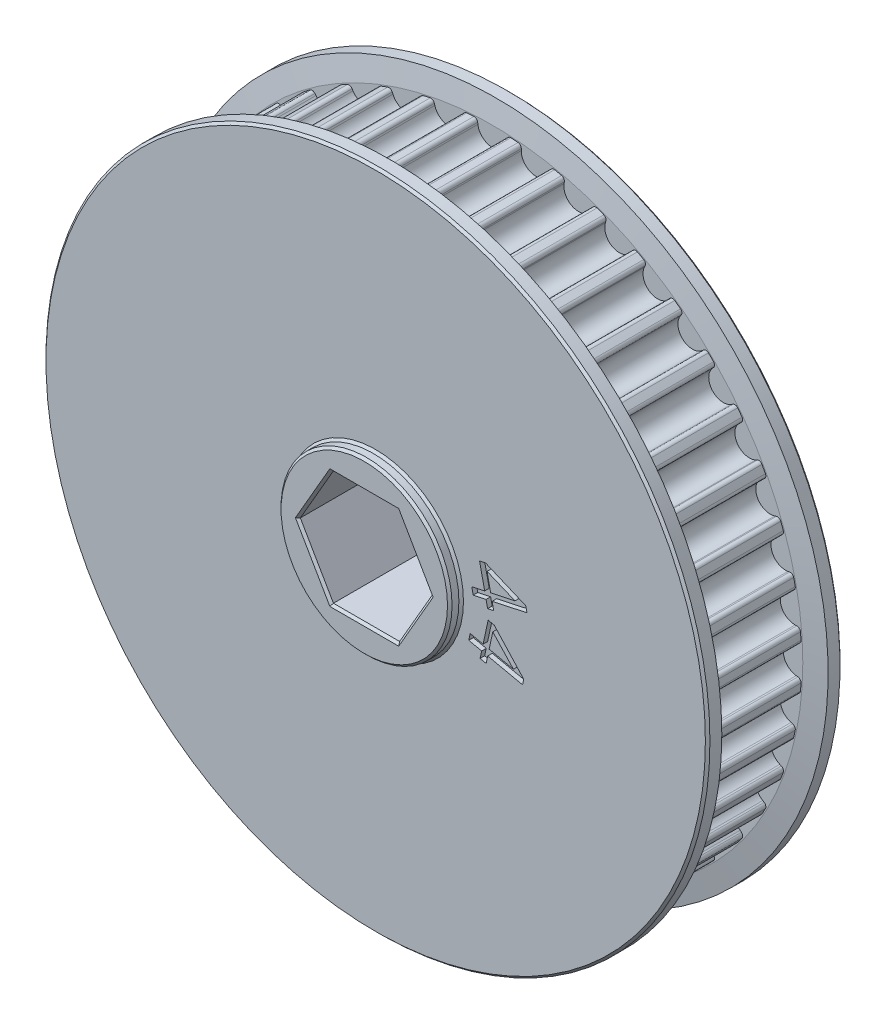
from build123d import *

# Parameters (mm, degrees)
SKETCH2_R                                 = 34.443854385
PULLEY_DEPTH                              = 5.500000049
CUT_TOOTH_DEPTH                           = 5.500000049
BLEND_TOOTH_R                             = 0.4
TOOTH_PATTERN_COUNT                       = 44
BLEND_TOOTH_OF_TOOTH_PATTERN_R            = 0.4
SIDEWALL_START                            = 5.500000049
SKETCH3_R                                 = 36.983854385
SIDEWALL_DEPTH                            = 2.000000064
SIDEWALL_CHAMFER_SIZE                     = 2.400000026
SIDEWALL_CHAMFER_SIZE2                    = 0.423184758
SIDEWALL_CHAMFER_PART_2_SIZE              = 2.400000026
SIDEWALL_CHAMFER_PART_2_SIZE2             = 0.423184758
SKETCH5_R                                 = 9.525
BEARING_SPACER_MANUAL_SUPPRESS_DEPTH      = 8.770000113
BEARING_SPACER_MANUAL_SUPPRESS_DEPTH_BACK = 8.770000113
HEX_SHAFT_DEPTH                           = 63.5
CHAMFERS_SIZE                             = 0.254
CUT_EXTRUDE_START                         = 6.992000113
CUT_EXTRUDE_4419_DEPTH                    = 2.54
SKETCH7_R                                 = 28.575
SKETCH7_R_2                               = 22.225
PATH_FOR_MOTOR_S_BOLTS_DEPTH              = 3.175


with BuildPart() as part:
    # Sketch2 → pulley (new body, symmetric)
    with BuildSketch(Plane.XY):
        Circle(SKETCH2_R)
    extrude(amount=PULLEY_DEPTH, both=True)

    # tooth → cut tooth (cut, symmetric)
    with BuildSketch(Plane.XY):
        with BuildLine():
            Line((-2.132711961, 38.079446832), (-1.612887548, 33.845816734))
            ThreePointArc((-1.612887548, 33.845816734), (0, 32.418854371), (1.612887548, 33.845816734))
            Line((1.612887548, 33.845816734), (2.132711961, 38.079446832))
            Line((2.132711961, 38.079446832), (-2.132711961, 38.079446832))
        make_face()
    cut_tooth = extrude(amount=CUT_TOOTH_DEPTH, both=True, mode=Mode.SUBTRACT)

    # blend tooth
    blend_tooth_edges = [part.edges().sort_by_distance(p)[0] for p in [
        (1.681276079, 34.402796626, 0),
        (-1.681276079, 34.402796626, 0),
    ]]
    fillet(blend_tooth_edges, radius=BLEND_TOOTH_R)

    # tooth pattern: cut tooth ×44 about axis
    tooth_pattern_axis = Axis((0, 0, 0), (0, 0, 1))
    for i in range(1, TOOTH_PATTERN_COUNT):
        add(cut_tooth.rotate(tooth_pattern_axis, i * 360 / TOOTH_PATTERN_COUNT), mode=Mode.SUBTRACT)

    # blend tooth of tooth pattern
    blend_tooth_of_tooth_pattern_edges = [part.edges().sort_by_distance(p)[0] for p in [
        (-3.231865325, 34.291896294, 0),
        (-6.560191551, 33.813355227, 0),
        (-8.079215271, 33.482911844, 0),
        (-11.305560441, 32.535571426, 0),
        (-12.762095693, 31.992311865, 0),
        (-15.820780722, 30.595457216, 0),
        (-17.185176649, 29.850440675, 0),
        (-20.013935532, 28.032507727, 0),
        (-21.258416967, 27.100900594, 0),
        (-23.799664329, 24.898897219, 0),
        (-24.898897219, 23.799664329, 0),
        (-27.100900594, 21.258416967, 0),
        (-28.032507727, 20.013935532, 0),
        (-29.850440675, 17.185176649, 0),
        (-30.595457216, 15.820780722, 0),
        (-31.992311865, 12.762095693, 0),
        (-32.535571426, 11.305560441, 0),
        (-33.482911844, 8.079215271, 0),
        (-33.813355227, 6.560191551, 0),
        (-34.291896294, 3.231865325, 0),
        (-34.402796626, 1.681276079, 0),
        (-34.402796626, -1.681276079, 0),
        (-34.291896294, -3.231865325, 0),
        (-33.813355227, -6.560191551, 0),
        (-33.482911844, -8.079215271, 0),
        (-32.535571426, -11.305560441, 0),
        (-31.992311865, -12.762095693, 0),
        (-30.595457216, -15.820780722, 0),
        (-29.850440675, -17.185176649, 0),
        (-28.032507727, -20.013935532, 0),
        (-27.100900594, -21.258416967, 0),
        (-24.898897219, -23.799664329, 0),
        (-23.799664329, -24.898897219, 0),
        (-21.258416967, -27.100900594, 0),
        (-20.013935532, -28.032507727, 0),
        (-17.185176649, -29.850440675, 0),
        (-15.820780722, -30.595457216, 0),
        (-12.762095693, -31.992311865, 0),
        (-11.305560441, -32.535571426, 0),
        (-8.079215271, -33.482911844, 0),
        (-6.560191551, -33.813355227, 0),
        (-3.231865325, -34.291896294, 0),
        (-1.681276079, -34.402796626, 0),
        (1.681276079, -34.402796626, 0),
        (3.231865325, -34.291896294, 0),
        (6.560191551, -33.813355227, 0),
        (8.079215271, -33.482911844, 0),
        (11.305560441, -32.535571426, 0),
        (12.762095693, -31.992311865, 0),
        (15.820780722, -30.595457216, 0),
        (17.185176649, -29.850440675, 0),
        (20.013935532, -28.032507727, 0),
        (21.258416967, -27.100900594, 0),
        (23.799664329, -24.898897219, 0),
        (24.898897219, -23.799664329, 0),
        (27.100900594, -21.258416967, 0),
        (28.032507727, -20.013935532, 0),
        (29.850440675, -17.185176649, 0),
        (30.595457216, -15.820780722, 0),
        (31.992311865, -12.762095693, 0),
        (32.535571426, -11.305560441, 0),
        (33.482911844, -8.079215271, 0),
        (33.813355227, -6.560191551, 0),
        (34.291896294, -3.231865325, 0),
        (34.402796626, -1.681276079, 0),
        (34.402796626, 1.681276079, 0),
        (34.291896294, 3.231865325, 0),
        (33.813355227, 6.560191551, 0),
        (33.482911844, 8.079215271, 0),
        (32.535571426, 11.305560441, 0),
        (31.992311865, 12.762095693, 0),
        (30.595457216, 15.820780722, 0),
        (29.850440675, 17.185176649, 0),
        (28.032507727, 20.013935532, 0),
        (27.100900594, 21.258416967, 0),
        (24.898897219, 23.799664329, 0),
        (23.799664329, 24.898897219, 0),
        (21.258416967, 27.100900594, 0),
        (20.013935532, 28.032507727, 0),
        (17.185176649, 29.850440675, 0),
        (15.820780722, 30.595457216, 0),
        (12.762095693, 31.992311865, 0),
        (11.305560441, 32.535571426, 0),
        (8.079215271, 33.482911844, 0),
        (6.560191551, 33.813355227, 0),
        (3.231865325, 34.291896294, 0),
    ]]
    fillet(blend_tooth_of_tooth_pattern_edges, radius=BLEND_TOOTH_OF_TOOTH_PATTERN_R)

    # Sketch3 → sidewall (add)
    with BuildSketch(Plane.XY.offset(SIDEWALL_START)):
        Circle(SKETCH3_R)
    sidewall = extrude(amount=SIDEWALL_DEPTH)

    # mirror sidewall: sidewall across plane
    add(sidewall.mirror(Plane.XY))

    # sidewall chamfer
    sidewall_chamfer_edges = [part.edges().sort_by_distance(p)[0] for p in [
        (-36.983854385, 0, 5.500000049),
    ]]
    sidewall_chamfer_side = [part.faces().sort_by_distance(p)[0] for p in [
        (-35.937793016, 0, 5.500000049),
    ]]
    chamfer(sidewall_chamfer_edges, length=SIDEWALL_CHAMFER_SIZE, length2=SIDEWALL_CHAMFER_SIZE2, reference=sidewall_chamfer_side[0])

    # sidewall chamfer part 2
    sidewall_chamfer_part_2_edges = [part.edges().sort_by_distance(p)[0] for p in [
        (-36.983854385, 0, -5.500000049),
    ]]
    sidewall_chamfer_part_2_side = [part.faces().sort_by_distance(p)[0] for p in [
        (-35.937793016, 0, -5.500000049),
    ]]
    chamfer(sidewall_chamfer_part_2_edges, length=SIDEWALL_CHAMFER_PART_2_SIZE, length2=SIDEWALL_CHAMFER_PART_2_SIZE2, reference=sidewall_chamfer_part_2_side[0])

    # Sketch5 → bearing spacer (Manual Suppress) (add, two sides)
    with BuildSketch(Plane.XY) as bearing_spacer_manual_suppress_sk:
        Circle(SKETCH5_R)
    extrude(amount=BEARING_SPACER_MANUAL_SUPPRESS_DEPTH)
    extrude(bearing_spacer_manual_suppress_sk.sketch, amount=-BEARING_SPACER_MANUAL_SUPPRESS_DEPTH_BACK)

    # Sketch4 → hex shaft (cut, symmetric)
    with BuildSketch(Plane.XY):
        Polygon((3.688171255, 6.3881), (-3.688171255, 6.3881), (-7.376342509, 0), (-3.688171255, -6.3881), (3.688171255, -6.3881), (7.376342509, 0), align=None)
    extrude(amount=HEX_SHAFT_DEPTH, both=True, mode=Mode.SUBTRACT)

    # chamfers
    chamfers_edges = [part.edges().sort_by_distance(p)[0] for p in [
        (-36.983854385, 0, 7.500000113),
        (-36.983854385, 0, -7.500000113),
        (-9.525, 0, -7.500000113),
        (-9.525, 0, 7.500000113),
        (-9.525, 0, -8.770000113),
        (-9.525, 0, 8.770000113),
        (0, 6.3881, 8.770000113),
        (-5.532256882, 3.19405, 8.770000113),
        (-5.532256882, -3.19405, 8.770000113),
        (0, -6.3881, 8.770000113),
        (5.532256882, -3.19405, 8.770000113),
        (5.532256882, 3.19405, 8.770000113),
        (5.532256882, 3.19405, -8.770000113),
        (5.532256882, -3.19405, -8.770000113),
        (0, -6.3881, -8.770000113),
        (-5.532256882, -3.19405, -8.770000113),
        (-5.532256882, 3.19405, -8.770000113),
        (0, 6.3881, -8.770000113),
    ]]
    chamfer(chamfers_edges, length=CHAMFERS_SIZE)

    # Sketch6 → 4419 (cut)
    with BuildSketch(Plane.XY.offset(CUT_EXTRUDE_START)):
        Polygon((10.702258848, 1.896432721), (12.138294728, 2.206359639), (11.576475016, 4.808017076), (12.25065867, 4.953719771), (16.727929609, 3.058349972), (16.857580311, 2.457017665), (12.971763532, 1.616140249), (13.147100673, 0.806132048), (12.472917018, 0.660429354), (12.297579877, 1.470437554), (10.861543997, 1.160510636), align=None)
        Polygon((12.812478383, 2.352062334), (15.516621613, 2.937342649), (12.406239514, 4.230145372), align=None, mode=Mode.SUBTRACT)
        Polygon((10.530143712, -2.707847537), (11.966179592, -3.017774455), (12.527999304, -0.416117018), (13.202182959, -0.561819712), (16.49654558, -4.138944342), (16.366894877, -4.74027665), (12.481078097, -3.899399234), (12.305740956, -4.709407435), (11.631557302, -4.56370474), (11.806894443, -3.75369654), (10.370858562, -3.443769621), align=None)
        Polygon((12.640363247, -3.16347715), (15.344506477, -3.748757465), (13.046602115, -1.285394111), align=None, mode=Mode.SUBTRACT)
    extrude(amount=CUT_EXTRUDE_4419_DEPTH, mode=Mode.SUBTRACT)

    # Sketch7 → Path for motor's bolts (cut)
    with BuildSketch(Plane(origin=(0, 0, -7.500000113), x_dir=(-1, 0, 0), z_dir=(0, 0, -1))):
        Circle(SKETCH7_R)
        Circle(SKETCH7_R_2, mode=Mode.SUBTRACT)
    extrude(amount=-PATH_FOR_MOTOR_S_BOLTS_DEPTH, mode=Mode.SUBTRACT)


solid = part.part
